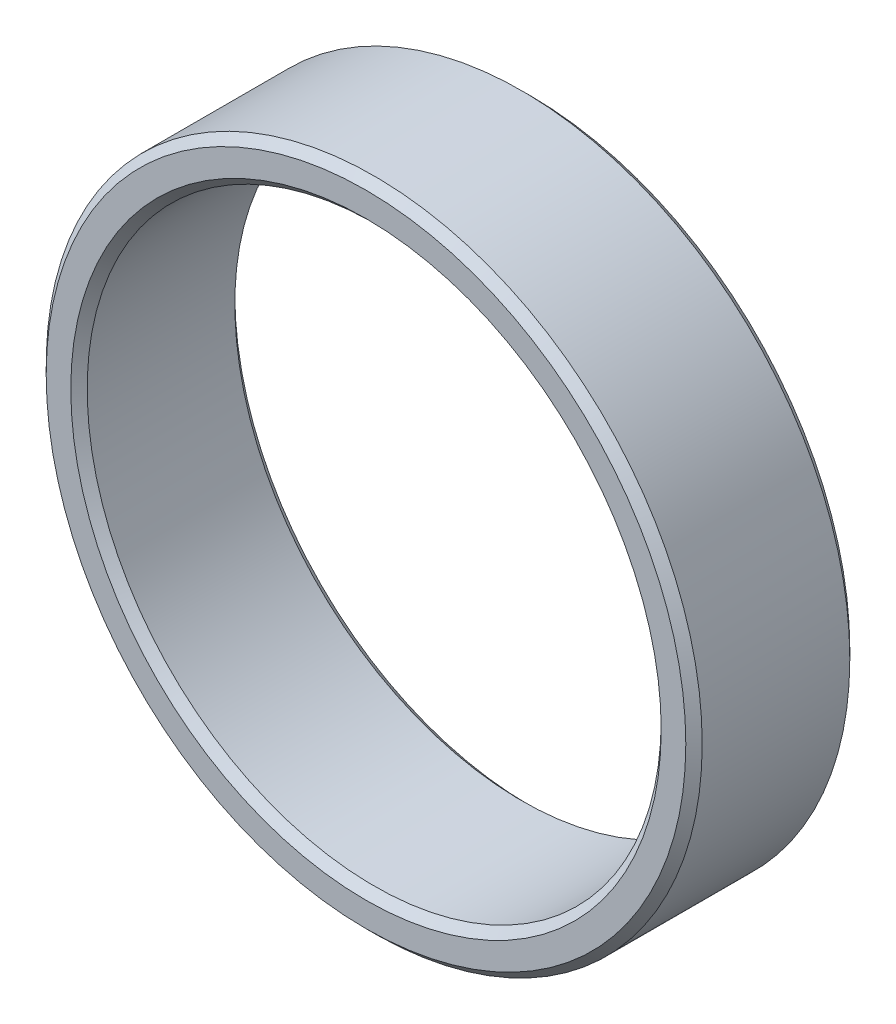
from build123d import *

# Parameters (mm, degrees)
ESQUISSE1_R          = 8
ESQUISSE1_R_2        = 7
BASE_EXTRUSION_DEPTH = 4
CHANFREIN1_SIZE      = 0.2


with BuildPart() as part:
    # Esquisse1 → Base-Extrusion (new body)
    with BuildSketch(Plane.XY):
        Circle(ESQUISSE1_R)
        Circle(ESQUISSE1_R_2, mode=Mode.SUBTRACT)
    extrude(amount=BASE_EXTRUSION_DEPTH)

    # Chanfrein1
    chanfrein1_edges = [part.edges().sort_by_distance(p)[0] for p in [
        (-8, 0, 0),
        (-8, 0, 4),
        (-7, 0, 0),
        (-7, 0, 4),
    ]]
    chamfer(chanfrein1_edges, length=CHANFREIN1_SIZE)


solid = part.part
